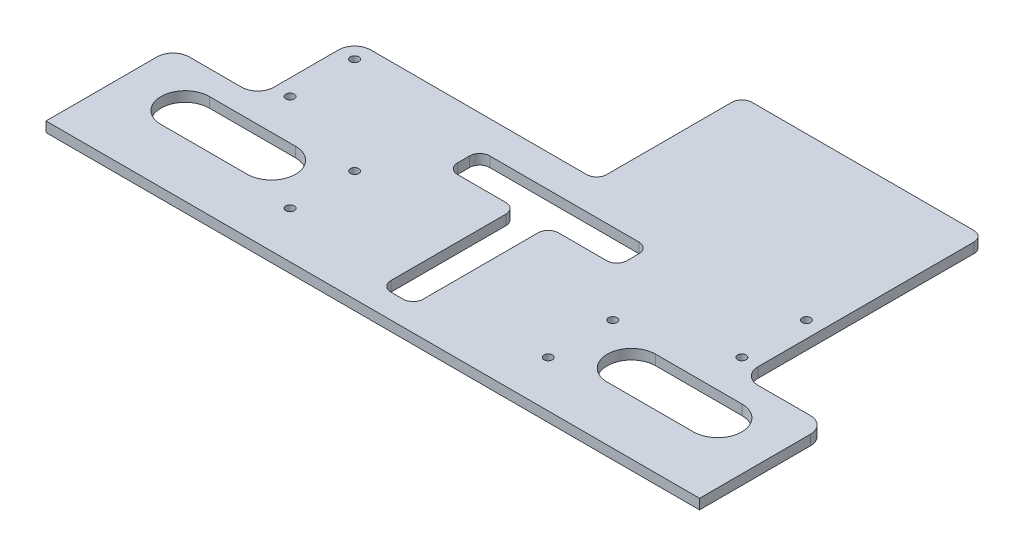
from build123d import *

# Parameters (mm, degrees)
SKETCH1_R               = 2.1
BOSS_EXTRUDE2_DEPTH     = 5
SKETCH2_W               = 324
SKETCH2_H               = 4
CUT_EXTRUDE1_DEPTH      = 1
CUT_EXTRUDE1_DEPTH_BACK = 6


with BuildPart() as part:
    # Sketch1 → Boss-Extrude2 (new body)
    with BuildSketch(Plane(origin=(0, 0, 0), x_dir=(1, 0, 0), z_dir=(0, 1, 0))):
        with BuildLine():
            Line((-112, 57.5), (-5, 57.5))
            ThreePointArc((-5, 57.5), (-1.464466094, 58.964466094), (0, 62.5))
            Line((0, 62.5), (0, 124.5))
            ThreePointArc((0, 124.5), (1.464466094, 128.035533906), (5, 129.5))
            Line((5, 129.5), (115, 129.5))
            ThreePointArc((115, 129.5), (118.535533906, 128.035533906), (120, 124.5))
            Line((120, 124.5), (120, 49.5))
            Line((120, 49.5), (120, 17.5))
            ThreePointArc((120, 17.5), (122.343145751, 11.843145751), (128, 9.5))
            Line((128, 9.5), (154, 9.5))
            ThreePointArc((154, 9.5), (159.656854249, 7.156854249), (162, 1.5))
            Line((162, 1.5), (162, -57.5))
            Line((162, -57.5), (-162, -57.5))
            Line((-162, -57.5), (-162, 1.5))
            ThreePointArc((-162, 1.5), (-159.656854249, 7.156854249), (-154, 9.5))
            Line((-154, 9.5), (-128, 9.5))
            ThreePointArc((-128, 9.5), (-122.343145751, 11.843145751), (-120, 17.5))
            Line((-120, 17.5), (-120, 49.5))
            ThreePointArc((-120, 49.5), (-117.656854249, 55.156854249), (-112, 57.5))
        make_face()
        with Locations((112, 49.5)):
            Circle(SKETCH1_R, mode=Mode.SUBTRACT)
        with Locations((112, 17.5)):
            Circle(SKETCH1_R, mode=Mode.SUBTRACT)
        with Locations((64, -30.5)):
            Circle(SKETCH1_R, mode=Mode.SUBTRACT)
        with Locations((64, 1.5)):
            Circle(SKETCH1_R, mode=Mode.SUBTRACT)
        with Locations((-112, 17.5)):
            Circle(SKETCH1_R, mode=Mode.SUBTRACT)
        with Locations((-112, 49.5)):
            Circle(SKETCH1_R, mode=Mode.SUBTRACT)
        with Locations((-64, 1.5)):
            Circle(SKETCH1_R, mode=Mode.SUBTRACT)
        with Locations((-64, -30.5)):
            Circle(SKETCH1_R, mode=Mode.SUBTRACT)
        with BuildLine():
            Line((8, 20.5), (8, -36.5))
            ThreePointArc((8, -36.5), (6.535533906, -40.035533906), (3, -41.5))
            Line((3, -41.5), (-3, -41.5))
            ThreePointArc((-3, -41.5), (-6.535533906, -40.035533906), (-8, -36.5))
            Line((-8, -36.5), (-8, 20.5))
            ThreePointArc((-8, 20.5), (-9.464466094, 24.035533906), (-13, 25.5))
            Line((-13, 25.5), (-37, 25.5))
            ThreePointArc((-37, 25.5), (-40.535533906, 26.964466094), (-42, 30.5))
            Line((-42, 30.5), (-42, 36.5))
            ThreePointArc((-42, 36.5), (-40.535533906, 40.035533906), (-37, 41.5))
            Line((-37, 41.5), (37, 41.5))
            ThreePointArc((37, 41.5), (40.535533906, 40.035533906), (42, 36.5))
            Line((42, 36.5), (42, 30.5))
            ThreePointArc((42, 30.5), (40.535533906, 26.964466094), (37, 25.5))
            Line((37, 25.5), (13, 25.5))
            ThreePointArc((13, 25.5), (9.464466094, 24.035533906), (8, 20.5))
        make_face(mode=Mode.SUBTRACT)
        with BuildLine():
            Line((132, -26.5), (89.247795496, -26.5))
            ThreePointArc((89.247795496, -26.5), (77.247795496, -14.5), (89.247795496, -2.5))
            Line((89.247795496, -2.5), (132, -2.5))
            ThreePointArc((132, -2.5), (144, -14.5), (132, -26.5))
        make_face(mode=Mode.SUBTRACT)
        with BuildLine():
            Line((-132, -26.5), (-89.247795496, -26.5))
            ThreePointArc((-89.247795496, -26.5), (-77.247795496, -14.5), (-89.247795496, -2.5))
            Line((-89.247795496, -2.5), (-132, -2.5))
            ThreePointArc((-132, -2.5), (-144, -14.5), (-132, -26.5))
        make_face(mode=Mode.SUBTRACT)
    extrude(amount=BOSS_EXTRUDE2_DEPTH)

    # Sketch2 → Cut-Extrude1 (cut, two sides)
    with BuildSketch(Plane(origin=(0, 5, 0), x_dir=(1, 0, 0), z_dir=(0, 1, 0))) as cut_extrude1_sk:
        with Locations((0, -55.5)):
            Rectangle(SKETCH2_W, SKETCH2_H)
    extrude(amount=CUT_EXTRUDE1_DEPTH, mode=Mode.SUBTRACT)
    extrude(cut_extrude1_sk.sketch, amount=-CUT_EXTRUDE1_DEPTH_BACK, mode=Mode.SUBTRACT)


solid = part.part
